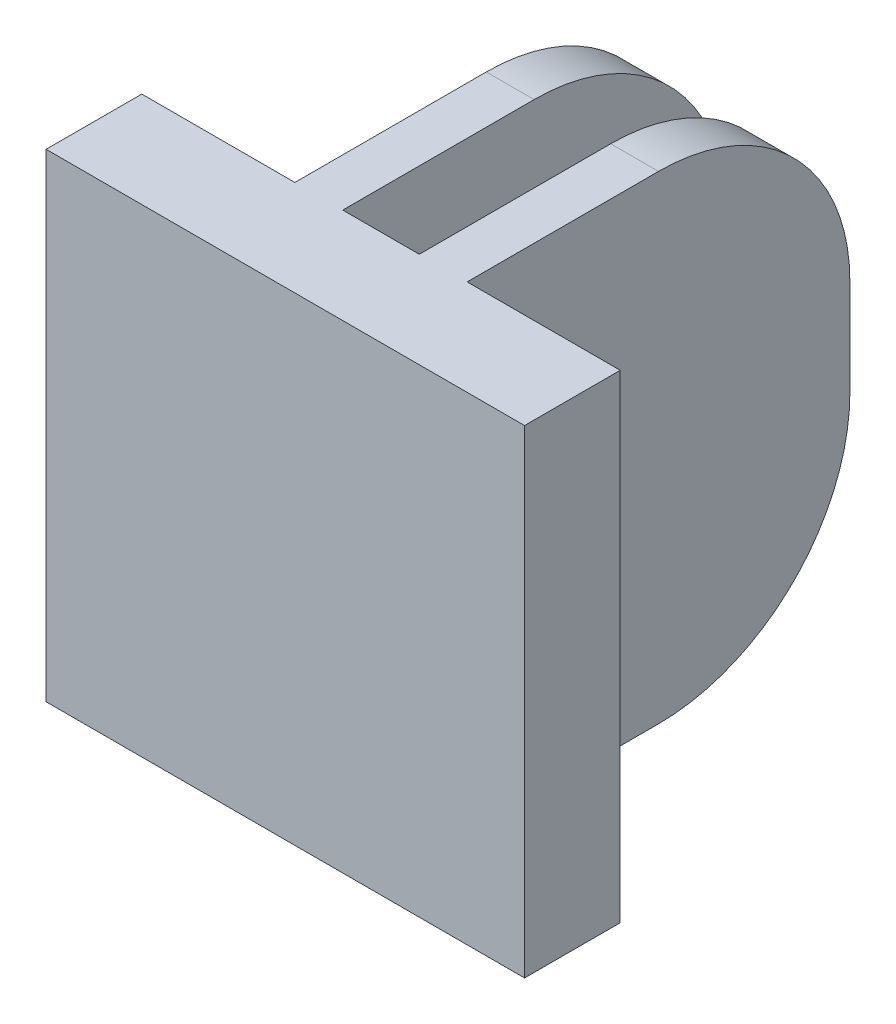
from build123d import *

# Parameters (mm, degrees)
SZKIC1_W                                   = 50
SZKIC1_H                                   = 50
DODANIE_WYCI_GNI_CIE1_DEPTH                = 10
SZKIC2_W                                   = 5
SZKIC2_H                                   = 50
DODANIE_WYCI_GNI_CIE2_DEPTH                = 40
WYCI_CIE_WYCI_GNI_CIE_CIENKA_CIANKA2_DEPTH = 40


with BuildPart() as part:
    # Szkic1 → Dodanie-wyciągnięcie1 (new body)
    with BuildSketch(Plane.XY):
        Rectangle(SZKIC1_W, SZKIC1_H)
    extrude(amount=DODANIE_WYCI_GNI_CIE1_DEPTH)

    # Szkic2 → Dodanie-wyciągnięcie2 (add)
    with BuildSketch(Plane(origin=(0, 0, 0), x_dir=(-1, 0, 0), z_dir=(0, 0, -1))):
        with Locations((-6.5, 0)):
            Rectangle(SZKIC2_W, SZKIC2_H)
        with Locations((6.5, 0)):
            Rectangle(SZKIC2_W, SZKIC2_H)
    extrude(amount=DODANIE_WYCI_GNI_CIE2_DEPTH)

    # Szkic4 → Wycięcie-wyciągnięcie-cienka ścianka2 (cut)
    with BuildSketch(Plane(origin=(9, 0, 0), x_dir=(0, 0, -1), z_dir=(1, 0, 0))):
        with BuildLine():
            ThreePointArc((40, -5), (34.142135624, -19.142135624), (20, -25))
            Line((20, -25), (20, -35))
            ThreePointArc((20, -35), (41.213203436, -26.213203436), (50, -5))
            Line((50, -5), (40, -5))
        make_face()
        with BuildLine():
            ThreePointArc((20, 25), (34.142135624, 19.142135624), (40, 5))
            Line((40, 5), (50, 5))
            ThreePointArc((50, 5), (41.213203436, 26.213203436), (20, 35))
            Line((20, 35), (20, 25))
        make_face()
    extrude(amount=-WYCI_CIE_WYCI_GNI_CIE_CIENKA_CIANKA2_DEPTH, mode=Mode.SUBTRACT)


solid = part.part
